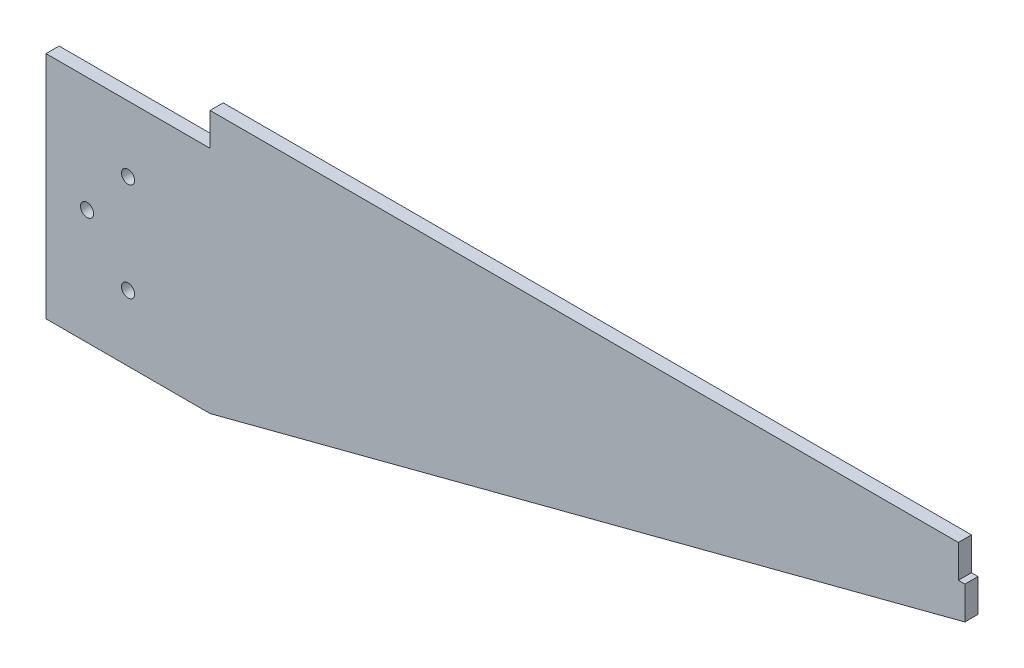
from build123d import *

# Parameters (mm, degrees)
BOSS_EXTRUDE1_DEPTH = 4
BOSS_EXTRUDE2_DEPTH = 4
CUT_EXTRUDE1_REACH  = 6
SKETCH3_R           = 2


with BuildPart() as part:
    # Sketch1 → Boss-Extrude1 (new body)
    with BuildSketch(Plane.XY):
        Polygon((128, 30.092990436), (128, 40.092990436), (-100, 40.092990436), (-100, 20.092990436), (-130, 20.092990436), (-130, -39.907009564), (-100, -39.907009564), (130, 20.092990436), (130, 30.092990436), align=None)
    extrude(amount=BOSS_EXTRUDE1_DEPTH)

    # Sketch2 → Boss-Extrude2 (add)
    with BuildSketch(Plane.XY.offset(4)):
        Polygon((-100, 30.092990436), (-150, 30.092990436), (-150, -39.907009564), (-130, -39.907009564), (-130, 20.092990436), (-100, 20.092990436), align=None)
    extrude(amount=-BOSS_EXTRUDE2_DEPTH)

    # Sketch3 → Cut-Extrude1 (cut, up to next)
    with BuildSketch(Plane.XY.offset(4), mode=Mode.PRIVATE) as cut_extrude1_sk1:
        with Locations((-125, 10.092990436)):
            Circle(SKETCH3_R)
    cut_extrude1_tool1 = extrude(cut_extrude1_sk1.sketch, amount=-CUT_EXTRUDE1_REACH, mode=Mode.PRIVATE) & part.part
    add(cut_extrude1_tool1.solids().sort_by_distance((-125, 10.09299, 4))[0], mode=Mode.SUBTRACT)
    # Sketch3 → Cut-Extrude1 (cut, up to next)
    with BuildSketch(Plane.XY.offset(4), mode=Mode.PRIVATE) as cut_extrude1_sk2:
        with Locations((-125, -19.907009564)):
            Circle(SKETCH3_R)
    cut_extrude1_tool2 = extrude(cut_extrude1_sk2.sketch, amount=-CUT_EXTRUDE1_REACH, mode=Mode.PRIVATE) & part.part
    add(cut_extrude1_tool2.solids().sort_by_distance((-125, -19.90701, 4))[0], mode=Mode.SUBTRACT)
    # Sketch3 → Cut-Extrude1 (cut, up to next)
    with BuildSketch(Plane.XY.offset(4), mode=Mode.PRIVATE) as cut_extrude1_sk3:
        with Locations((-137.5, -4.907009564)):
            Circle(SKETCH3_R)
    cut_extrude1_tool3 = extrude(cut_extrude1_sk3.sketch, amount=-CUT_EXTRUDE1_REACH, mode=Mode.PRIVATE) & part.part
    add(cut_extrude1_tool3.solids().sort_by_distance((-137.5, -4.90701, 4))[0], mode=Mode.SUBTRACT)


solid = part.part
